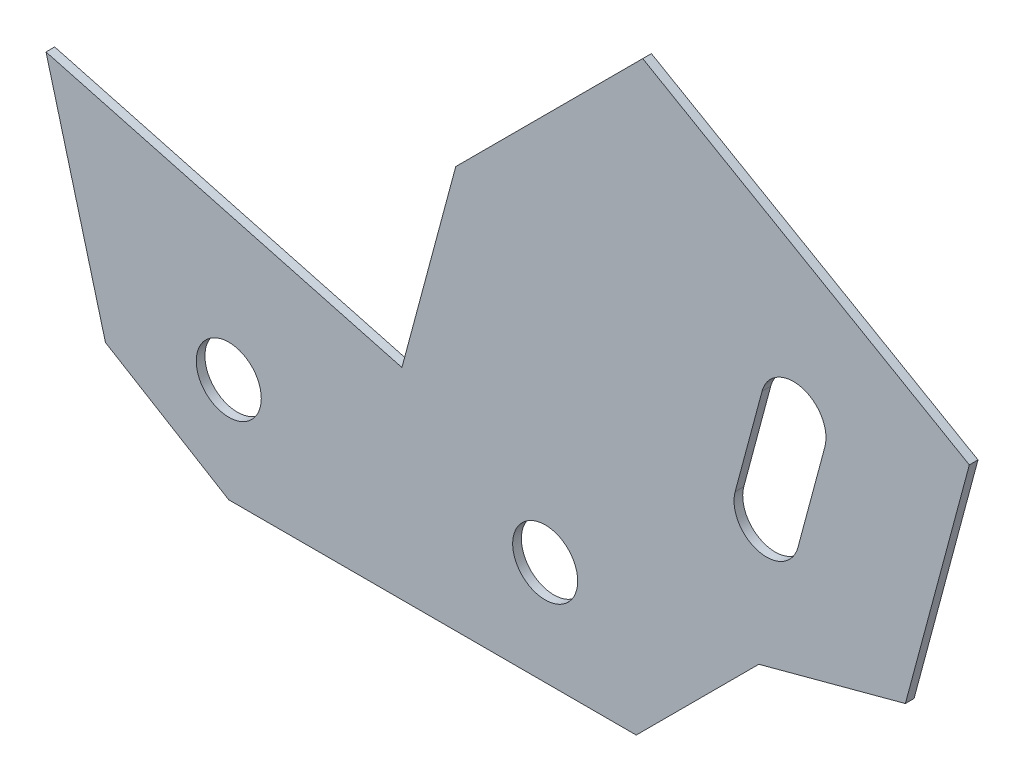
from build123d import *

# Parameters (mm, degrees)
SKETCH1_R           = 7.5
BOSS_EXTRUDE1_DEPTH = 2


with BuildPart() as part:
    # Sketch1 → Boss-Extrude1 (new body)
    with BuildSketch(Plane.XY):
        Polygon((-73, -24), (21, -24), (49.284271247, 4.284271247), (83.091675168, 13.342937826), (97.844360738, 68.400709925), (22.500150609, 111.900709925), (-20.633363043, 68.767196272), (-33.056677208, 22.40275661), (-115.160372443, 44.402375444), (-101.442963052, -6.791693349), align=None)
        Circle(SKETCH1_R, mode=Mode.SUBTRACT)
        with Locations((-73, 0)):
            Circle(SKETCH1_R, mode=Mode.SUBTRACT)
        with BuildLine():
            Line((64.520092973, 55.334506438), (58.308435891, 32.152286607))
            ThreePointArc((58.308435891, 32.152286607), (49.122849355, 26.848985748), (43.819548496, 36.034572283))
            Line((43.819548496, 36.034572283), (50.031205579, 59.216792114))
            ThreePointArc((50.031205579, 59.216792114), (59.216792114, 64.520092973), (64.520092973, 55.334506438))
        make_face(mode=Mode.SUBTRACT)
    extrude(amount=BOSS_EXTRUDE1_DEPTH)


solid = part.part
